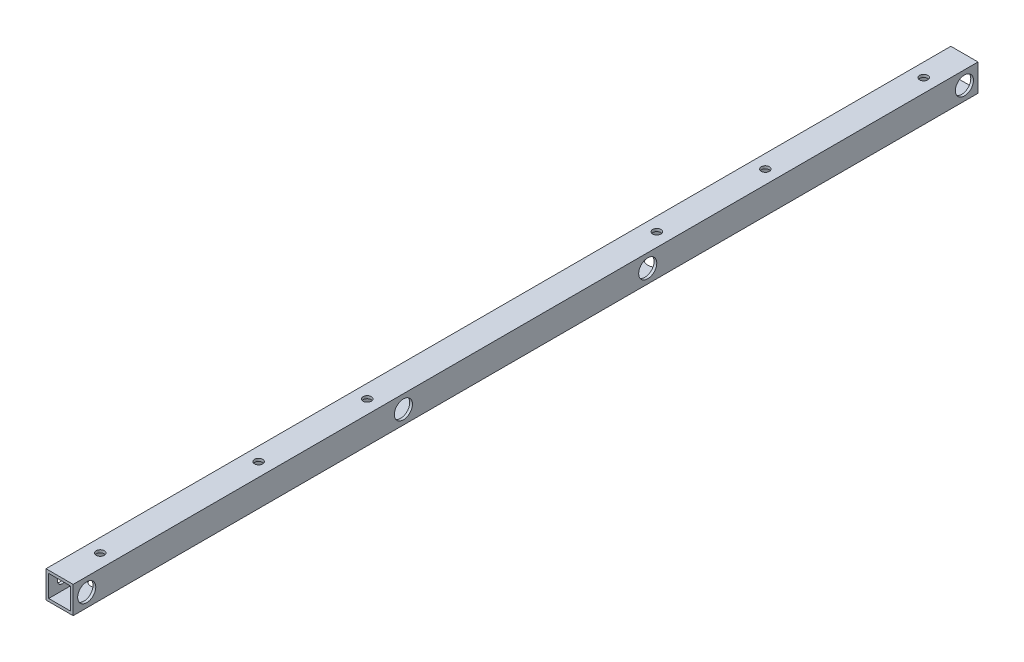
from build123d import *

# Parameters (mm, degrees)
SKETCH_1_W          = 15
SKETCH_1_H          = 15
SKETCH_1_W_2        = 12
SKETCH_1_H_2        = 12
EXTRUDE_1_DEPTH     = 500
SKETCH_2_R          = 2.7
CUT_EXTRUDE_1_DEPTH = 25
SKETCH_3_R          = 2.25
CUT_EXTRUDE_2_DEPTH = 25
SKETCH_4_R          = 2.25
CUT_EXTRUDE_3_DEPTH = 20
SKETCH_5_R          = 5
CUT_EXTRUDE_4_DEPTH = 10
SKETCH_6_R          = 5
CUT_EXTRUDE_5_DEPTH = 10


with BuildPart() as part:
    # ｽｹｯﾁ1 → ﾎﾞｽ - 押し出し1 (new body)
    with BuildSketch(Plane.XY):
        Rectangle(SKETCH_1_W, SKETCH_1_H)
        Rectangle(SKETCH_1_W_2, SKETCH_1_H_2, mode=Mode.SUBTRACT)
    extrude(amount=EXTRUDE_1_DEPTH)

    # ｽｹｯﾁ2 → ｶｯﾄ - 押し出し1 (cut)
    with BuildSketch(Plane(origin=(7.5, 0, 0), x_dir=(0, 0, -1), z_dir=(1, 0, 0))):
        with Locations((-492.5, 0)):
            Circle(SKETCH_2_R)
        with Locations((-7.5, 0)):
            Circle(SKETCH_2_R)
        with Locations((-317.5, 0)):
            Circle(SKETCH_2_R)
        with Locations((-182.5, 0)):
            Circle(SKETCH_2_R)
    extrude(amount=-CUT_EXTRUDE_1_DEPTH, mode=Mode.SUBTRACT)

    # ｽｹｯﾁ3 → ｶｯﾄ - 押し出し2 (cut)
    with BuildSketch(Plane(origin=(0, 7.5, 0), x_dir=(1, 0, 0), z_dir=(0, 1, 0))):
        with Locations((0, -22.5)):
            Circle(SKETCH_3_R)
        with Locations((0, -477.5)):
            Circle(SKETCH_3_R)
    extrude(amount=-CUT_EXTRUDE_2_DEPTH, mode=Mode.SUBTRACT)

    # ｽｹｯﾁ4 → ｶｯﾄ - 押し出し3 (cut)
    with BuildSketch(Plane(origin=(0, -7.5, 0), x_dir=(-1, 0, 0), z_dir=(0, -1, 0))):
        with Locations((0, -390)):
            Circle(SKETCH_4_R)
        with Locations((0, -330)):
            Circle(SKETCH_4_R)
        with Locations((0, -110)):
            Circle(SKETCH_4_R)
        with Locations((0, -170)):
            Circle(SKETCH_4_R)
    extrude(amount=-CUT_EXTRUDE_3_DEPTH, mode=Mode.SUBTRACT)

    # ｽｹｯﾁ5 → ｶｯﾄ - 押し出し4 (cut)
    with BuildSketch(Plane(origin=(0, -7.5, 0), x_dir=(1, 0, 0), z_dir=(0, 1, 0))):
        with Locations((0, -22.5)):
            Circle(SKETCH_5_R)
        with Locations((0, -477.5)):
            Circle(SKETCH_5_R)
        with Locations((0, -390)):
            Circle(SKETCH_5_R)
        with Locations((0, -330)):
            Circle(SKETCH_5_R)
        with Locations((0, -110)):
            Circle(SKETCH_5_R)
        with Locations((0, -170)):
            Circle(SKETCH_5_R)
    extrude(amount=CUT_EXTRUDE_4_DEPTH, mode=Mode.SUBTRACT)

    # ｽｹｯﾁ6 → ｶｯﾄ - 押し出し5 (cut)
    with BuildSketch(Plane(origin=(7.5, 0, 0), x_dir=(0, 0, -1), z_dir=(1, 0, 0))):
        with Locations((-492.5, 0)):
            Circle(SKETCH_6_R)
        with Locations((-317.5, 0)):
            Circle(SKETCH_6_R)
        with Locations((-182.5, 0)):
            Circle(SKETCH_6_R)
        with Locations((-7.5, 0)):
            Circle(SKETCH_6_R)
    extrude(amount=-CUT_EXTRUDE_5_DEPTH, mode=Mode.SUBTRACT)


solid = part.part
